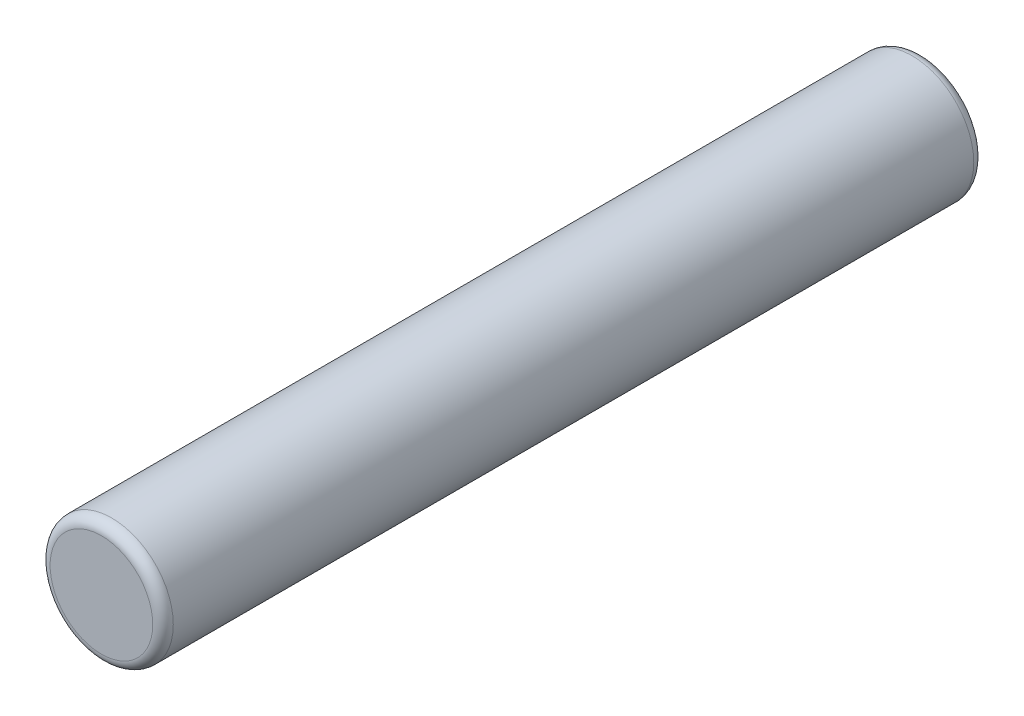
from build123d import *

# Parameters (mm, degrees)
SKETCH1_R           = 6
BOSS_EXTRUDE1_DEPTH = 80
FILLET1_R           = 1


with BuildPart() as part:
    # Sketch1 → Boss-Extrude1 (new body)
    with BuildSketch(Plane.XY):
        Circle(SKETCH1_R)
    extrude(amount=BOSS_EXTRUDE1_DEPTH)

    # Fillet1
    fillet1_edges = [part.edges().sort_by_distance(p)[0] for p in [
        (-6, 0, 0),
        (-6, 0, 80),
    ]]
    fillet(fillet1_edges, radius=FILLET1_R)


solid = part.part
